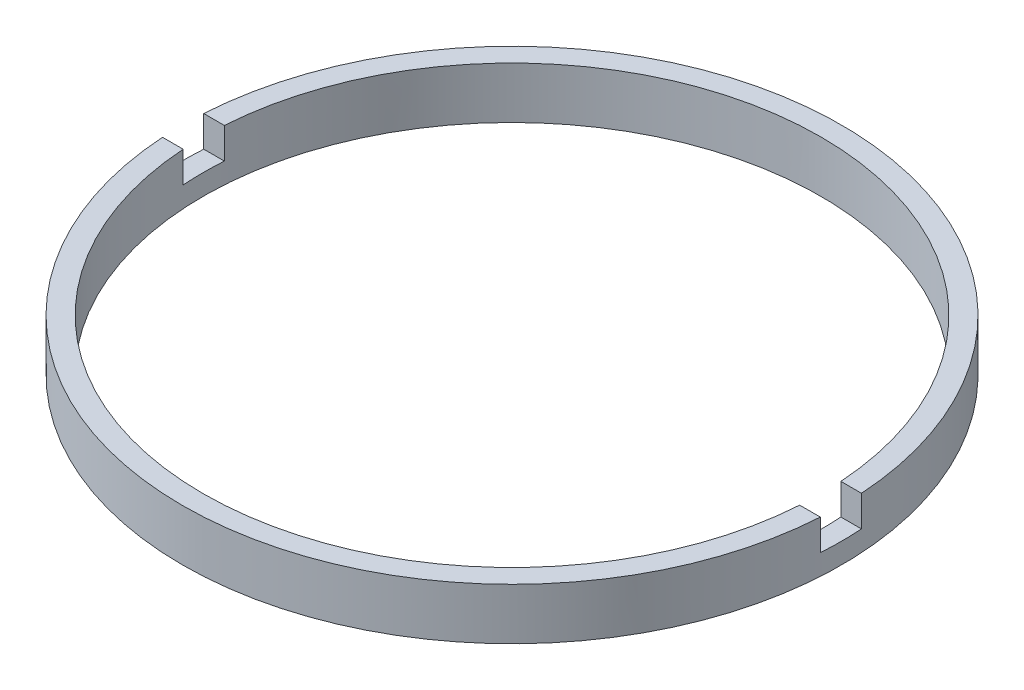
from build123d import *

# Parameters (mm, degrees)
SKETCH_1_W          = 1
SKETCH_1_H          = 2.5
SKETCH_2_W          = 53.705080546
SKETCH_2_H          = 2
CUT_EXTRUDE_1_DEPTH = 1.5


with BuildPart() as part:
    # 草图1 → 旋转1 (revolve)
    with BuildSketch(Plane.XY, mode=Mode.PRIVATE) as revolve_1_sk:
        with Locations((15.5, -3.214249787)):
            Rectangle(SKETCH_1_W, SKETCH_1_H)
    revolve(revolve_1_sk.sketch.rotate(Axis((0, 56.260842627, 0), (0, -1, 0)), 90), axis=Axis((0, 56.260842627, 0), (0, -1, 0)))  # turned: the seam where the file's is

    # 草图2 → 切除-拉伸1 (cut)
    with BuildSketch(Plane(origin=(0, -1.964249787, 0), x_dir=(1, 0, 0), z_dir=(0, 1, 0))):
        Rectangle(SKETCH_2_W, SKETCH_2_H)
    extrude(amount=-CUT_EXTRUDE_1_DEPTH, mode=Mode.SUBTRACT)


solid = part.part
